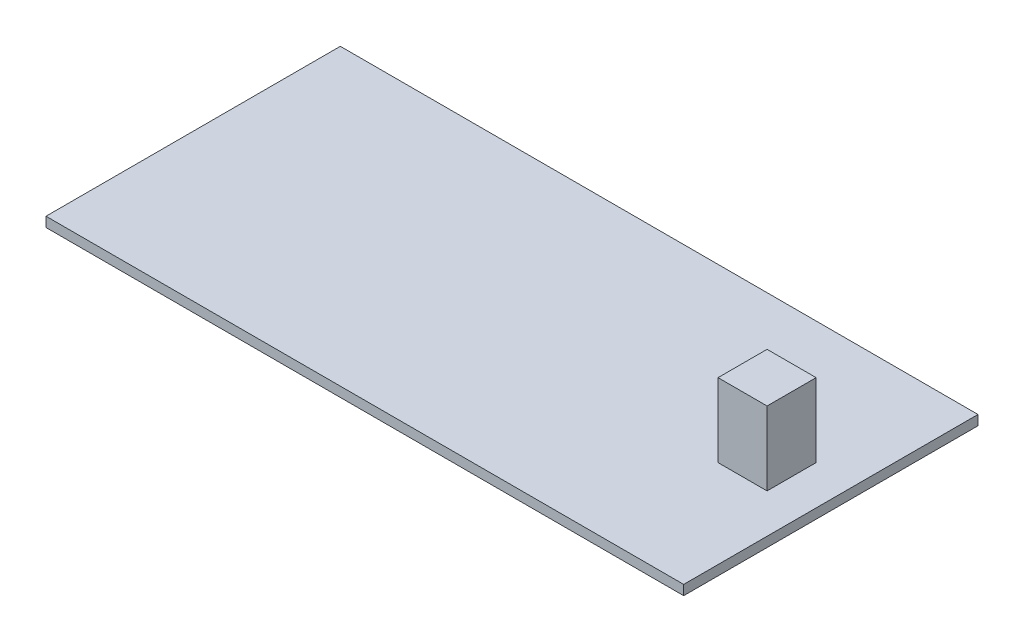
from build123d import *

# Parameters (mm, degrees)
SKETCH1_W           = 300
SKETCH1_H           = 300
SKETCH1_W_2         = 350
BOSS_EXTRUDE1_DEPTH = 5
SKETCH2_W           = 50
SKETCH2_H           = 50
BOSS_EXTRUDE2_DEPTH = 75


with BuildPart() as part:
    # Sketch1 → Boss-Extrude1 (new body, symmetric)
    with BuildSketch(Plane(origin=(0, 0, 0), x_dir=(1, 0, 0), z_dir=(0, 1, 0))):
        Rectangle(SKETCH1_W, SKETCH1_H)
        with Locations((325, 0)):
            Rectangle(SKETCH1_W_2, SKETCH1_H)
    extrude(amount=BOSS_EXTRUDE1_DEPTH, both=True)

    # Sketch2 → Boss-Extrude2 (add)
    with BuildSketch(Plane(origin=(0, 5, 0), x_dir=(1, 0, 0), z_dir=(0, 1, 0))):
        with Locations((435, 0)):
            Rectangle(SKETCH2_W, SKETCH2_H)
    extrude(amount=BOSS_EXTRUDE2_DEPTH)


solid = part.part
